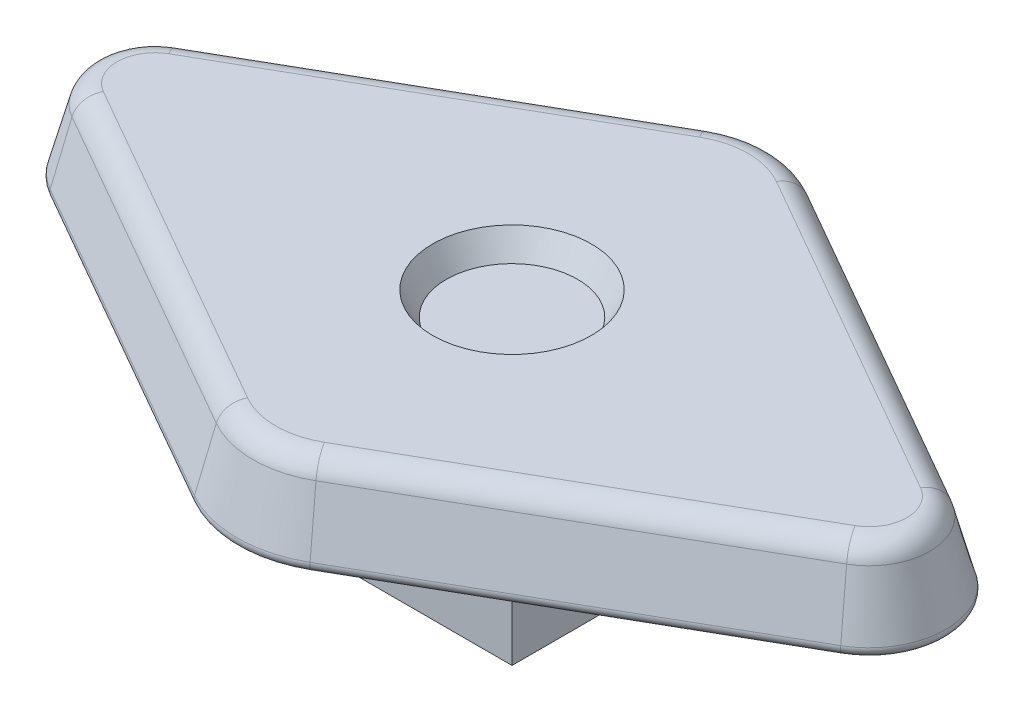
from build123d import *

# Parameters (mm, degrees)
SKETCH1_W           = 2.54
SKETCH1_H           = 2.54
BOSS_EXTRUDE1_DEPTH = 2.54
BOSS_EXTRUDE2_DEPTH = 1.397
BOSS_EXTRUDE2_TAPER = 15
FILLET1_R           = 0.381
FILLET2_R           = 0.127
SKETCH3_R           = 1.27
CUT_EXTRUDE1_DEPTH  = 0.381
CUT_EXTRUDE1_TAPER  = 30


with BuildPart() as part:
    # Sketch1 → Boss-Extrude1 (new body)
    with BuildSketch(Plane(origin=(0, 0, 0), x_dir=(1, 0, 0), z_dir=(0, 1, 0))):
        Rectangle(SKETCH1_W, SKETCH1_H)
    extrude(amount=BOSS_EXTRUDE1_DEPTH)

    # Sketch2 → Boss-Extrude2 (add)
    with BuildSketch(Plane(origin=(0, 2.54, 0), x_dir=(1, 0, 0), z_dir=(0, 1, 0))):
        with BuildLine():
            Line((6.345965274, 1.102171866), (0.946447911, 4.1932578))
            ThreePointArc((0.946447911, 4.1932578), (0, 4.445), (-0.946447911, 4.1932578))
            Line((-0.946447911, 4.1932578), (-6.345965274, 1.102171866))
            ThreePointArc((-6.345965274, 1.102171866), (-6.985, 0), (-6.345965274, -1.102171866))
            Line((-6.345965274, -1.102171866), (-0.946447911, -4.1932578))
            ThreePointArc((-0.946447911, -4.1932578), (0, -4.445), (0.946447911, -4.1932578))
            Line((0.946447911, -4.1932578), (6.345965274, -1.102171866))
            ThreePointArc((6.345965274, -1.102171866), (6.985, 0), (6.345965274, 1.102171866))
        make_face()
    extrude(amount=BOSS_EXTRUDE2_DEPTH, taper=BOSS_EXTRUDE2_TAPER)

    # Fillet1
    fillet1_edges = [part.edges().sort_by_distance(p)[0] for p in [
        (0, 3.937, -4.070674978),
        (-3.460233293, 3.937, -2.322856165),
        (-6.610674978, 3.937, 0),
        (-3.460233293, 3.937, 2.322856165),
        (0, 3.937, 4.070674978),
        (3.460233293, 3.937, 2.322856165),
        (6.610674978, 3.937, 0),
        (3.460233293, 3.937, -2.322856165),
    ]]
    fillet(fillet1_edges, radius=FILLET1_R)

    # Fillet2
    fillet2_edges = [part.edges().sort_by_distance(p)[0] for p in [
        (0, 2.54, -4.445),
        (-3.646206592, 2.54, -2.647714833),
        (-6.985, 2.54, 0),
        (-3.646206592, 2.54, 2.647714833),
        (0, 2.54, 4.445),
        (3.646206592, 2.54, 2.647714833),
        (6.985, 2.54, 0),
        (3.646206592, 2.54, -2.647714833),
    ]]
    fillet(fillet2_edges, radius=FILLET2_R)

    # Sketch3 → Cut-Extrude1 (cut)
    with BuildSketch(Plane(origin=(0, 3.937, 0), x_dir=(1, 0, 0), z_dir=(0, 1, 0))):
        Circle(SKETCH3_R)
    extrude(amount=-CUT_EXTRUDE1_DEPTH, taper=CUT_EXTRUDE1_TAPER, mode=Mode.SUBTRACT)


solid = part.part
